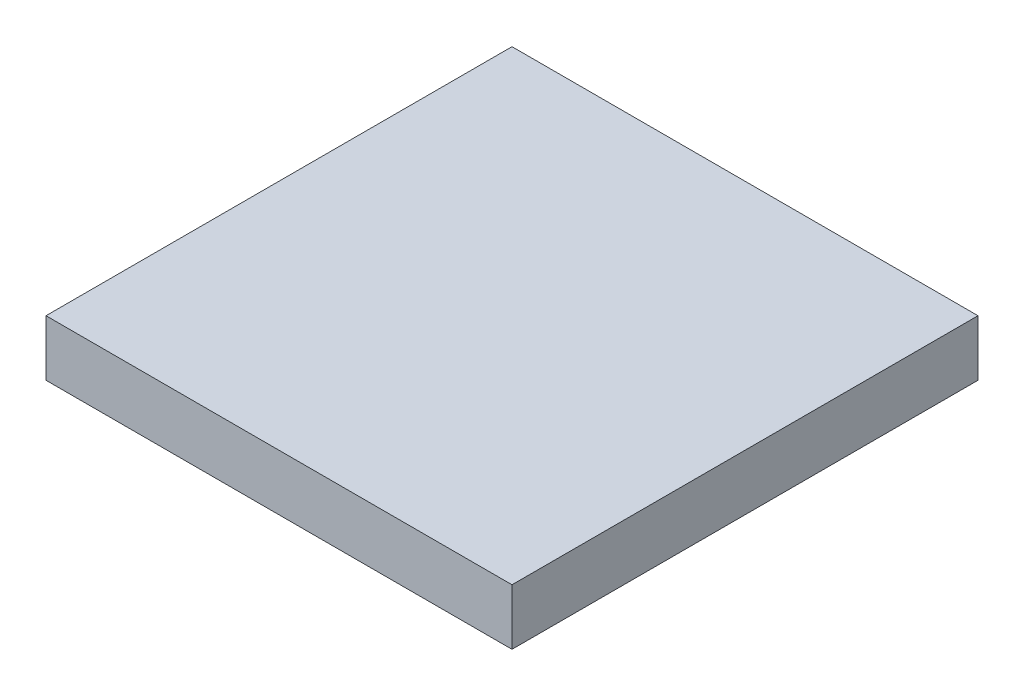
from build123d import *

# Parameters (mm, degrees)
SKETCH1_W           = 25
SKETCH1_H           = 25
BOSS_EXTRUDE1_DEPTH = 3
SKETCH2_W           = 20
SKETCH2_H           = 20
SKETCH2_R           = 5
CUT_EXTRUDE1_DEPTH  = 2
SKETCH3_R           = 1.25
CUT_EXTRUDE2_DEPTH  = 2


with BuildPart() as part:
    # Sketch1 → Boss-Extrude1 (new body)
    with BuildSketch(Plane(origin=(0, 0, 0), x_dir=(1, 0, 0), z_dir=(0, 1, 0))):
        Rectangle(SKETCH1_W, SKETCH1_H)
    extrude(amount=BOSS_EXTRUDE1_DEPTH)

    # Sketch2 → Cut-Extrude1 (cut)
    with BuildSketch(Plane.XZ):
        Rectangle(SKETCH2_W, SKETCH2_H)
        Circle(SKETCH2_R, mode=Mode.SUBTRACT)
    extrude(amount=-CUT_EXTRUDE1_DEPTH, mode=Mode.SUBTRACT)

    # Sketch3 → Cut-Extrude2 (cut)
    with BuildSketch(Plane.XZ):
        with Locations((-11, 11)):
            Circle(SKETCH3_R)
        with Locations((11, 11)):
            Circle(SKETCH3_R)
        with Locations((11, -11)):
            Circle(SKETCH3_R)
        with Locations((-11, -11)):
            Circle(SKETCH3_R)
    extrude(amount=-CUT_EXTRUDE2_DEPTH, mode=Mode.SUBTRACT)


solid = part.part
